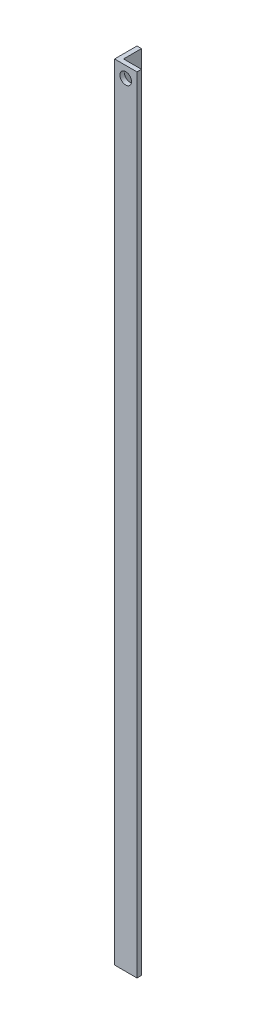
from build123d import *

# Parameters (mm, degrees)
BOSS_EXTRUDE1_DEPTH        = 350
F_6_0_204_DIAMETER_HOLE2_D = 5.1816
F_6_0_204_DIAMETER_HOLE3_D = 5.1816


with BuildPart() as part:
    # Sketch1 → Boss-Extrude1 (new body)
    with BuildSketch(Plane(origin=(0, 0, 0), x_dir=(1, 0, 0), z_dir=(0, 1, 0))):
        Polygon((0, 0), (0, 10), (2, 10), (2, 2), (10, 2), (10, 0), align=None)
    extrude(amount=BOSS_EXTRUDE1_DEPTH)

    # #6 (0.204) Diameter Hole2 (through all)
    with Locations(Plane.ZY):
        with Locations((-5, 5)):
            Hole(F_6_0_204_DIAMETER_HOLE2_D / 2)

    # #6 (0.204) Diameter Hole3 (through all)
    with Locations(Plane.XY):
        with Locations((5, 345)):
            Hole(F_6_0_204_DIAMETER_HOLE3_D / 2)


solid = part.part
